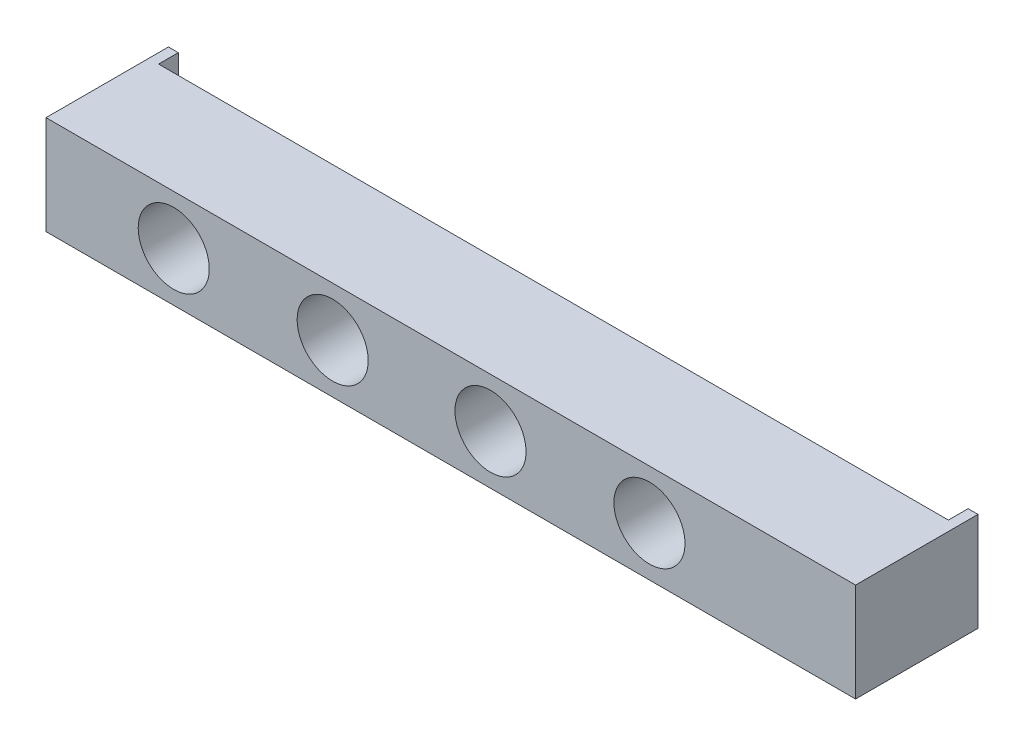
from build123d import *

# Parameters (mm, degrees)
SKIZZE1_W                        = 205
SKIZZE1_H                        = 25
AUFSATZ_LINEAR_AUSTRAGEN1_DEPTH  = 26
SKIZZE2_W                        = 2.5
SKIZZE2_H                        = 25
AUFSATZ_LINEAR_AUSTRAGEN2_DEPTH  = 5
F_18_0_18_DURCHMESSER_BOHRUNG1_D = 18


with BuildPart() as part:
    # Skizze1 → Aufsatz-Linear austragen1 (new body)
    with BuildSketch(Plane.XY):
        with Locations((102.5, 12.5)):
            Rectangle(SKIZZE1_W, SKIZZE1_H)
    extrude(amount=AUFSATZ_LINEAR_AUSTRAGEN1_DEPTH)

    # Skizze2 → Aufsatz-Linear austragen2 (add)
    with BuildSketch(Plane(origin=(0, 0, 0), x_dir=(-1, 0, 0), z_dir=(0, 0, -1))):
        with Locations((-1.25, 12.5)):
            Rectangle(SKIZZE2_W, SKIZZE2_H)
        with Locations((-203.75, 12.5)):
            Rectangle(SKIZZE2_W, SKIZZE2_H)
    extrude(amount=AUFSATZ_LINEAR_AUSTRAGEN2_DEPTH)

    # Ø18.0 (18) Durchmesser Bohrung1 (through all)
    with Locations(Plane(origin=(0, 0, 0), x_dir=(-1, 0, 0), z_dir=(0, 0, -1))):
        with Locations((-32.344324412, 12.5), (-72.588665447, 12.5), (-112.561085259, 12.5), (-152.805426293, 12.5)):
            Hole(F_18_0_18_DURCHMESSER_BOHRUNG1_D / 2)


solid = part.part
